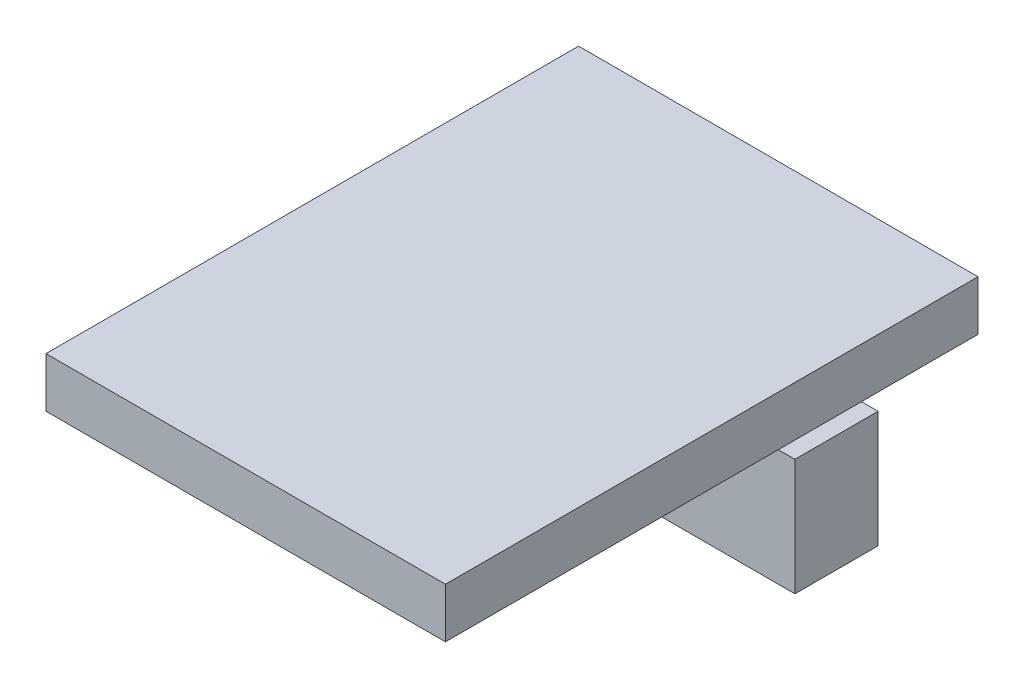
from build123d import *

# Parameters (mm, degrees)
SKETCH1_W           = 24
SKETCH1_H           = 32
BOSS_EXTRUDE1_DEPTH = 3
SKETCH2_W           = 1.5
SKETCH2_H           = 3
BOSS_EXTRUDE5_DEPTH = 6
SKETCH3_W           = 20
SKETCH3_H           = 5
BOSS_EXTRUDE6_DEPTH = 7


with BuildPart() as part:
    # Sketch1 → Boss-Extrude1 (new body)
    with BuildSketch(Plane(origin=(0, 0, 0), x_dir=(1, 0, 0), z_dir=(0, 1, 0))):
        with Locations((-10.330434783, 1.634782609)):
            Rectangle(SKETCH1_W, SKETCH1_H)
    extrude(amount=BOSS_EXTRUDE1_DEPTH)

    # Sketch2 → Boss-Extrude5 (add)
    with BuildSketch(Plane(origin=(0, 3, 0), x_dir=(1, 0, 0), z_dir=(0, 1, 0))):
        with Locations((-14.580434783, 11.134782609)):
            Rectangle(SKETCH2_W, SKETCH2_H)
        with Locations((-6.080434783, 11.134782609)):
            Rectangle(SKETCH2_W, SKETCH2_H)
    extrude(amount=-BOSS_EXTRUDE5_DEPTH)

    # Sketch3 → Boss-Extrude6 (add)
    with BuildSketch(Plane.XZ.offset(3)):
        with Locations((-10.330434783, -11.134782609)):
            Rectangle(SKETCH3_W, SKETCH3_H)
    extrude(amount=BOSS_EXTRUDE6_DEPTH)


solid = part.part
